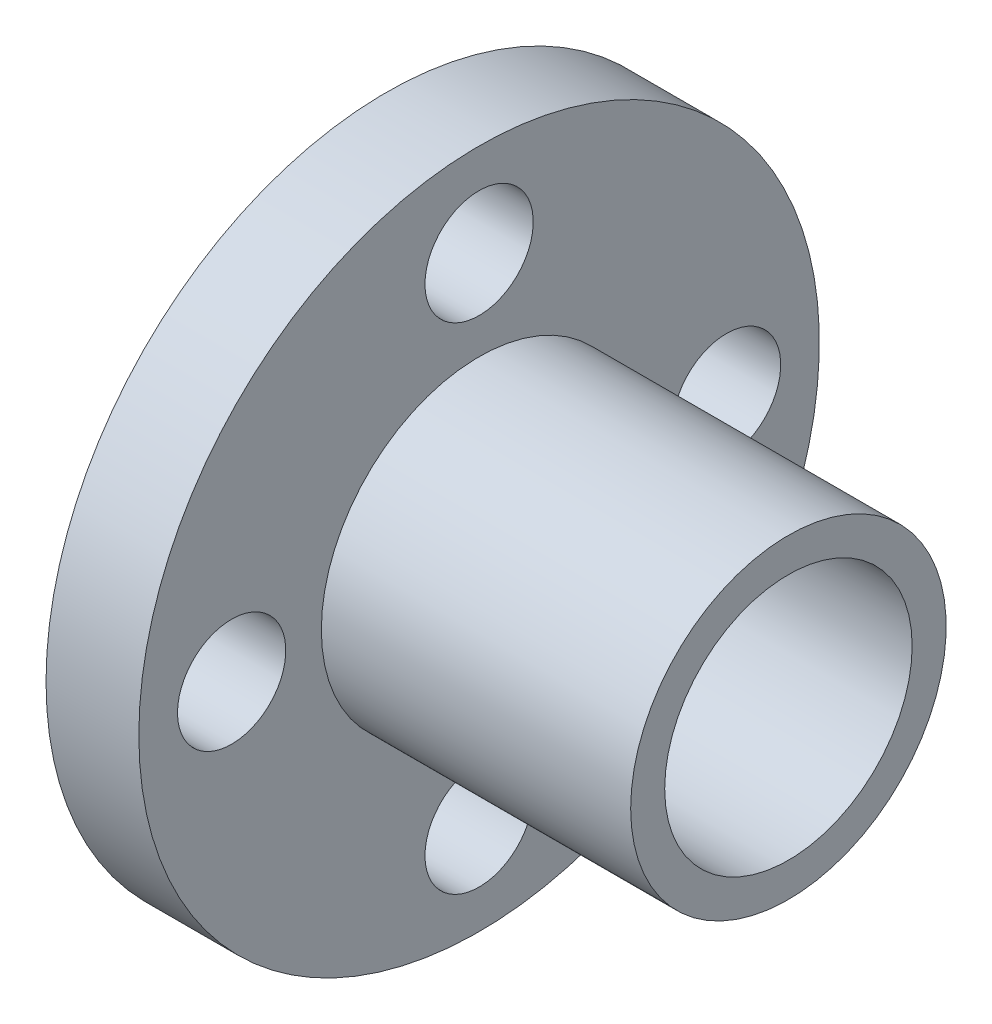
from build123d import *

# Parameters (mm, degrees)
SKETCH3_R          = 1.75
CUT_EXTRUDE2_DEPTH = 3


with BuildPart() as part:
    # Sketch1 → Revolve1 (revolve)
    with BuildSketch(Plane.XY):
        Polygon((-5.75, -5.1), (-5.75, -11), (-2.75, -11), (-2.75, -5.1), (7.25, -5.1), (7.25, -4), (-7.25, -4), (-7.25, -5.1), align=None)
    revolve(axis=Axis((-7.25, 0, 0), (1, 0, 0)))

    # Sketch3 → Cut-Extrude2 (cut)
    with BuildSketch(Plane.ZY.offset(5.75)):
        with Locations((0, 8)):
            Circle(SKETCH3_R)
        with Locations((0, -8)):
            Circle(SKETCH3_R)
        with Locations((8, 0)):
            Circle(SKETCH3_R)
        with Locations((-8, 0)):
            Circle(SKETCH3_R)
        Polygon((5205.178442712, 2346.745629148), (5205.178442712, 2340.845629148), (5208.178442712, 2340.845629148), (5208.178442712, 2346.745629148), (5218.178442712, 2346.745629148), (5218.178442712, 2347.845629148), (5203.678442712, 2347.845629148), (5203.678442712, 2346.745629148), align=None)
    extrude(amount=-CUT_EXTRUDE2_DEPTH, mode=Mode.SUBTRACT)


solid = part.part
